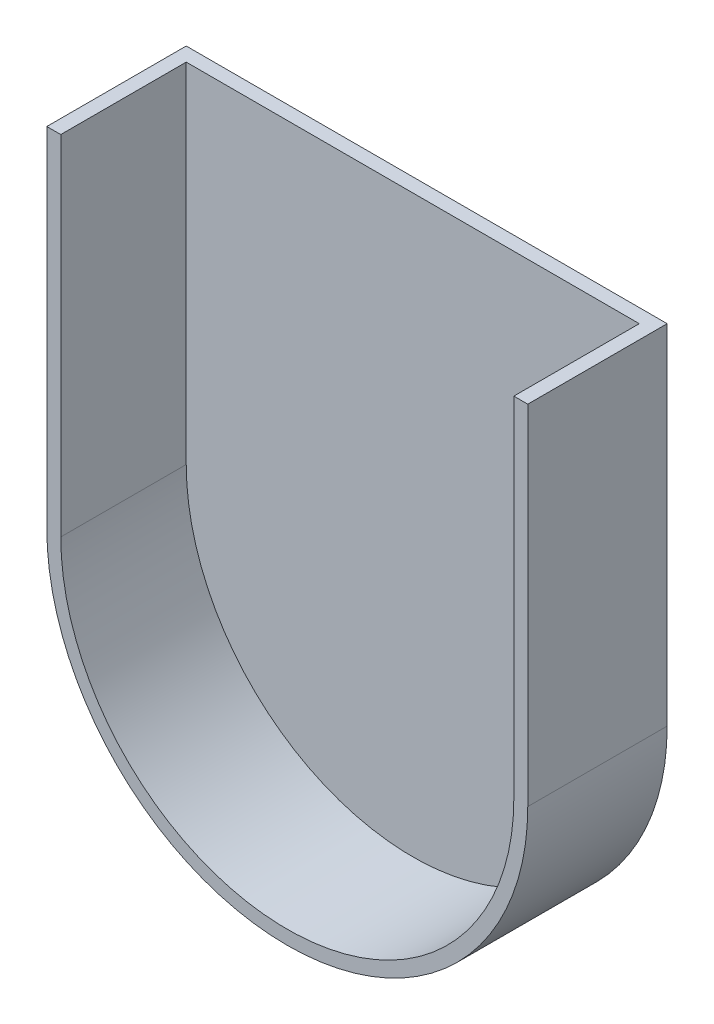
from build123d import *

# Parameters (mm, degrees)
DODANIE_WYCI_GNI_CIE1_DEPTH = 20
DODANIE_WYCI_GNI_CIE2_DEPTH = 2


with BuildPart() as part:
    # Szkic1 → Dodanie-wyci_gni_cie1 (new body)
    with BuildSketch(Plane.XY):
        with BuildLine():
            ThreePointArc((-34.5, 0), (0, -34.5), (34.5, 0))
            Line((34.5, 0), (34.5, 50))
            Line((34.5, 50), (32.5, 50))
            Line((32.5, 50), (32.5, 0))
            ThreePointArc((32.5, 0), (0, -32.5), (-32.5, 0))
            Line((-32.5, 0), (-32.5, 50))
            Line((-32.5, 50), (-34.5, 50))
            Line((-34.5, 50), (-34.5, 0))
        make_face()
    extrude(amount=DODANIE_WYCI_GNI_CIE1_DEPTH)

    # Szkic1_3 → Dodanie-wyci_gni_cie2 (add)
    with BuildSketch(Plane.XY):
        with BuildLine():
            Line((32.5, 0), (32.5, 50))
            Line((32.5, 50), (-32.5, 50))
            Line((-32.5, 50), (-32.5, 0))
            ThreePointArc((-32.5, 0), (0, -32.5), (32.5, 0))
        make_face()
    extrude(amount=DODANIE_WYCI_GNI_CIE2_DEPTH)


solid = part.part
